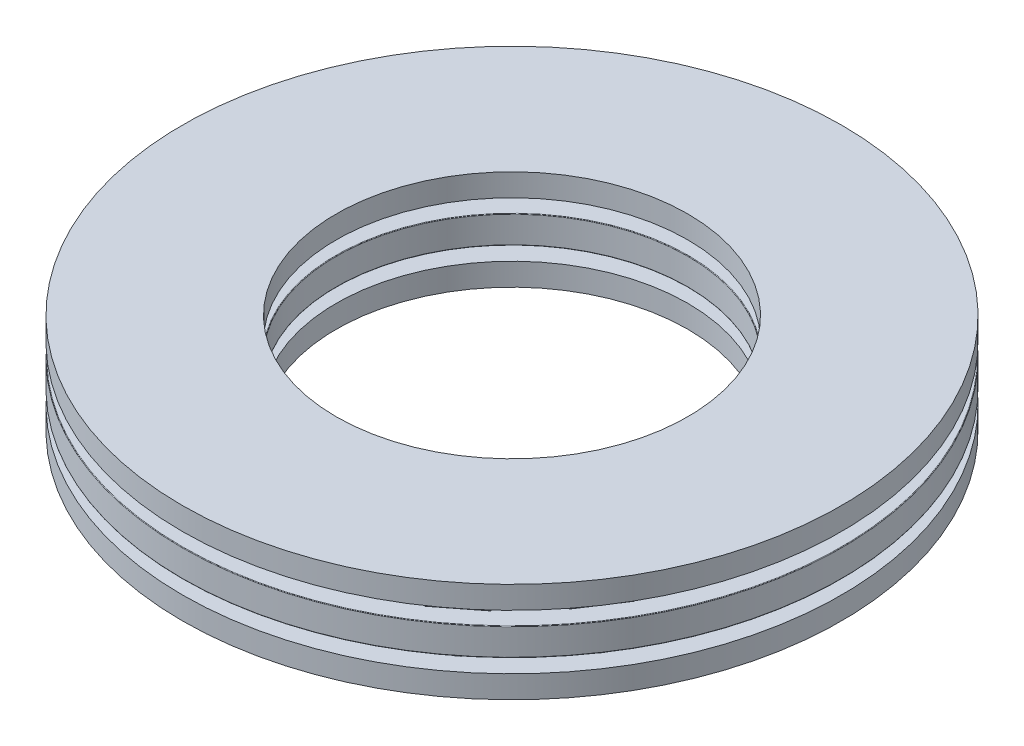
from build123d import *

# Parameters (mm, degrees)
SKETCH1_W         = 5.55625
SKETCH1_H         = 0.9921875
SKETCH3_W         = 4.1671875
SKETCH3_H         = 0.9921875
SKETCH2_W         = 4.1671875
SKETCH2_H         = 0.9921875
CIRPATTERN1_COUNT = 19
CIRPATTERN1_ANGLE = 341.052631579
CIRPATTERN2_COUNT = 19
SKETCH4_W         = 5.55625
SKETCH4_H         = 0.8128
FILLET2_R         = 0.01984375


with BuildPart() as part:
    # Sketch1 → Revolve1 (revolve)
    with BuildSketch(Plane(origin=(0, 0, 0), x_dir=(0, 0, -1), z_dir=(1, 0, 0)), mode=Mode.PRIVATE) as revolve1_sk:
        with Locations((-9.128125, 0)):
            Rectangle(SKETCH1_W, SKETCH1_H)
    revolve(revolve1_sk.sketch.rotate(Axis((0, -0.9921875, 0), (0, 1, 0)), 180), axis=Axis((0, -0.9921875, 0), (0, 1, 0)))

    # Sketch3 → Cut-Revolve1 (revolve, cut)
    with BuildSketch(Plane(origin=(0, 0, 0), x_dir=(0, 0, -1), z_dir=(1, 0, 0))):
        with Locations((-9.128125, 0.49609375)):
            Rectangle(SKETCH3_W, SKETCH3_H)
    cut_revolve1 = revolve(axis=Axis((0, 0, 11.21171875), (0, 0, -1)), mode=Mode.SUBTRACT)

    # CirPattern2: Cut-Revolve1 ×19 about axis
    cirpattern2_axis = Axis((0, 0, 0), (0, 1, 0))
    for i in range(1, CIRPATTERN2_COUNT):
        add(cut_revolve1.rotate(cirpattern2_axis, i * 360 / CIRPATTERN2_COUNT), mode=Mode.SUBTRACT)

    # Fillet2
    fillet2_edges = [part.edges().sort_by_distance(p)[0] for p in [
        (0, 0.49609375, 11.90625),
        (0, 0.49609375, 6.35),
        (0, -0.49609375, 6.35),
        (0, -0.49609375, 11.90625),
    ]]
    fillet(fillet2_edges, radius=FILLET2_R)


with BuildPart() as body_2:
    # Sketch2 → Revolve2 (revolve)
    with BuildSketch(Plane(origin=(0, 0, 0), x_dir=(0, 0, -1), z_dir=(1, 0, 0)), mode=Mode.PRIVATE) as revolve2_sk:
        with Locations((-9.128125, 0.49609375)):
            Rectangle(SKETCH2_W, SKETCH2_H)
    revolve(revolve2_sk.sketch.rotate(Axis((0, 0, 11.21171875), (0, 0, -1)), 90), axis=Axis((0, 0, 11.21171875), (0, 0, -1)))


with BuildPart() as cirpattern1_1:
    # CirPattern1: pattern copy
    add(body_2.part.rotate(Axis((0, 0.9921875, 0), (0, -1, 0)), 1 * CIRPATTERN1_ANGLE / (CIRPATTERN1_COUNT - 1)))


with BuildPart() as cirpattern1_2:
    # CirPattern1: pattern copy
    add(body_2.part.rotate(Axis((0, 0.9921875, 0), (0, -1, 0)), 2 * CIRPATTERN1_ANGLE / (CIRPATTERN1_COUNT - 1)))


with BuildPart() as cirpattern1_3:
    # CirPattern1: pattern copy
    add(body_2.part.rotate(Axis((0, 0.9921875, 0), (0, -1, 0)), 3 * CIRPATTERN1_ANGLE / (CIRPATTERN1_COUNT - 1)))


with BuildPart() as cirpattern1_4:
    # CirPattern1: pattern copy
    add(body_2.part.rotate(Axis((0, 0.9921875, 0), (0, -1, 0)), 4 * CIRPATTERN1_ANGLE / (CIRPATTERN1_COUNT - 1)))


with BuildPart() as cirpattern1_5:
    # CirPattern1: pattern copy
    add(body_2.part.rotate(Axis((0, 0.9921875, 0), (0, -1, 0)), 5 * CIRPATTERN1_ANGLE / (CIRPATTERN1_COUNT - 1)))


with BuildPart() as cirpattern1_6:
    # CirPattern1: pattern copy
    add(body_2.part.rotate(Axis((0, 0.9921875, 0), (0, -1, 0)), 6 * CIRPATTERN1_ANGLE / (CIRPATTERN1_COUNT - 1)))


with BuildPart() as cirpattern1_7:
    # CirPattern1: pattern copy
    add(body_2.part.rotate(Axis((0, 0.9921875, 0), (0, -1, 0)), 7 * CIRPATTERN1_ANGLE / (CIRPATTERN1_COUNT - 1)))


with BuildPart() as cirpattern1_8:
    # CirPattern1: pattern copy
    add(body_2.part.rotate(Axis((0, 0.9921875, 0), (0, -1, 0)), 8 * CIRPATTERN1_ANGLE / (CIRPATTERN1_COUNT - 1)))


with BuildPart() as cirpattern1_9:
    # CirPattern1: pattern copy
    add(body_2.part.rotate(Axis((0, 0.9921875, 0), (0, -1, 0)), 9 * CIRPATTERN1_ANGLE / (CIRPATTERN1_COUNT - 1)))


with BuildPart() as cirpattern1_10:
    # CirPattern1: pattern copy
    add(body_2.part.rotate(Axis((0, 0.9921875, 0), (0, -1, 0)), 10 * CIRPATTERN1_ANGLE / (CIRPATTERN1_COUNT - 1)))


with BuildPart() as cirpattern1_11:
    # CirPattern1: pattern copy
    add(body_2.part.rotate(Axis((0, 0.9921875, 0), (0, -1, 0)), 11 * CIRPATTERN1_ANGLE / (CIRPATTERN1_COUNT - 1)))


with BuildPart() as cirpattern1_12:
    # CirPattern1: pattern copy
    add(body_2.part.rotate(Axis((0, 0.9921875, 0), (0, -1, 0)), 12 * CIRPATTERN1_ANGLE / (CIRPATTERN1_COUNT - 1)))


with BuildPart() as cirpattern1_13:
    # CirPattern1: pattern copy
    add(body_2.part.rotate(Axis((0, 0.9921875, 0), (0, -1, 0)), 13 * CIRPATTERN1_ANGLE / (CIRPATTERN1_COUNT - 1)))


with BuildPart() as cirpattern1_14:
    # CirPattern1: pattern copy
    add(body_2.part.rotate(Axis((0, 0.9921875, 0), (0, -1, 0)), 14 * CIRPATTERN1_ANGLE / (CIRPATTERN1_COUNT - 1)))


with BuildPart() as cirpattern1_15:
    # CirPattern1: pattern copy
    add(body_2.part.rotate(Axis((0, 0.9921875, 0), (0, -1, 0)), 15 * CIRPATTERN1_ANGLE / (CIRPATTERN1_COUNT - 1)))


with BuildPart() as cirpattern1_16:
    # CirPattern1: pattern copy
    add(body_2.part.rotate(Axis((0, 0.9921875, 0), (0, -1, 0)), 16 * CIRPATTERN1_ANGLE / (CIRPATTERN1_COUNT - 1)))


with BuildPart() as cirpattern1_17:
    # CirPattern1: pattern copy
    add(body_2.part.rotate(Axis((0, 0.9921875, 0), (0, -1, 0)), 17 * CIRPATTERN1_ANGLE / (CIRPATTERN1_COUNT - 1)))


with BuildPart() as cirpattern1_18:
    # CirPattern1: pattern copy
    add(body_2.part.rotate(Axis((0, 0.9921875, 0), (0, -1, 0)), 18 * CIRPATTERN1_ANGLE / (CIRPATTERN1_COUNT - 1)))


with BuildPart() as body_21:
    # Sketch4 → Revolve3 (revolve)
    with BuildSketch(Plane(origin=(0, 0, 0), x_dir=(0, 0, -1), z_dir=(1, 0, 0)), mode=Mode.PRIVATE) as revolve3_sk:
        with Locations((-9.128125, 1.3985875)):
            Rectangle(SKETCH4_W, SKETCH4_H)
        with Locations((-9.128125, -1.3985875)):
            Rectangle(SKETCH4_W, SKETCH4_H)
    revolve(revolve3_sk.sketch.rotate(Axis((0, -0.9921875, 0), (0, 1, 0)), 180), axis=Axis((0, -0.9921875, 0), (0, 1, 0)))


solid = Compound([part.part, body_2.part, cirpattern1_1.part, cirpattern1_2.part, cirpattern1_3.part, cirpattern1_4.part, cirpattern1_5.part, cirpattern1_6.part, cirpattern1_7.part, cirpattern1_8.part, cirpattern1_9.part, cirpattern1_10.part, cirpattern1_11.part, cirpattern1_12.part, cirpattern1_13.part, cirpattern1_14.part, cirpattern1_15.part, cirpattern1_16.part, cirpattern1_17.part, cirpattern1_18.part, body_21.part])
